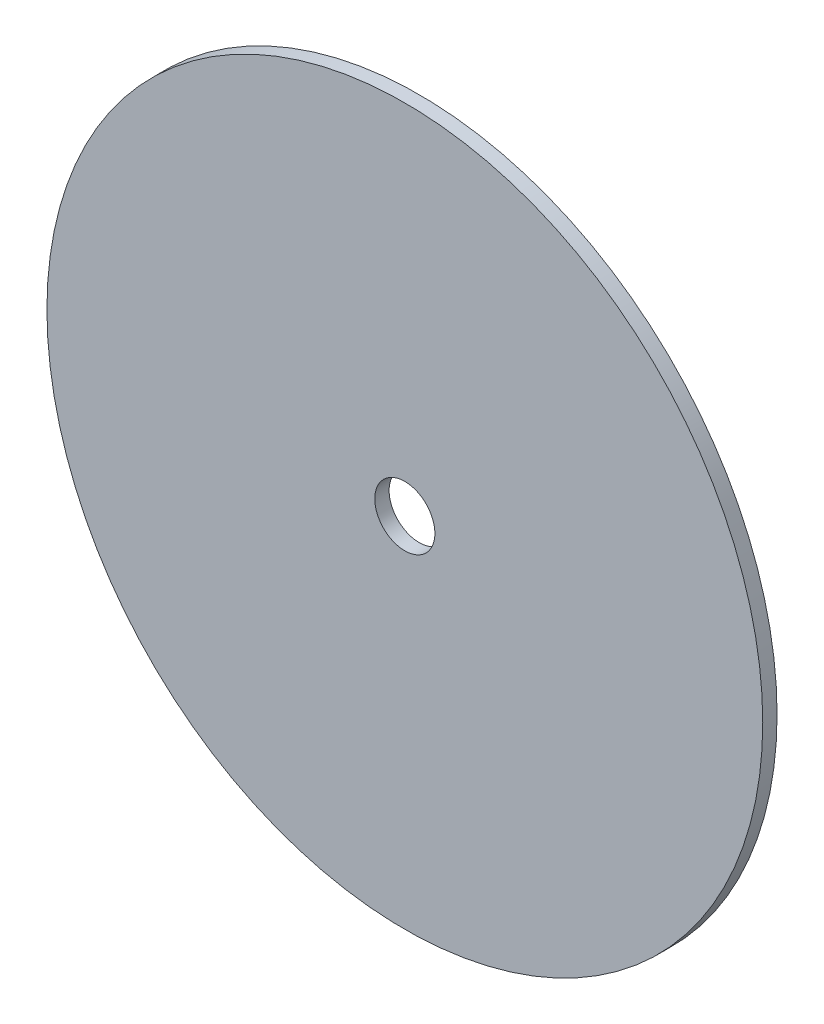
from build123d import *

# Parameters (mm, degrees)
ESQUISSE1_R        = 150
ESQUISSE1_R_2      = 12.6
BOSS_EXTRU_1_DEPTH = 6


with BuildPart() as part:
    # Esquisse1 → Boss.-Extru.1 (new body)
    with BuildSketch(Plane.XY):
        Circle(ESQUISSE1_R)
        Circle(ESQUISSE1_R_2, mode=Mode.SUBTRACT)
    extrude(amount=BOSS_EXTRU_1_DEPTH)


solid = part.part
